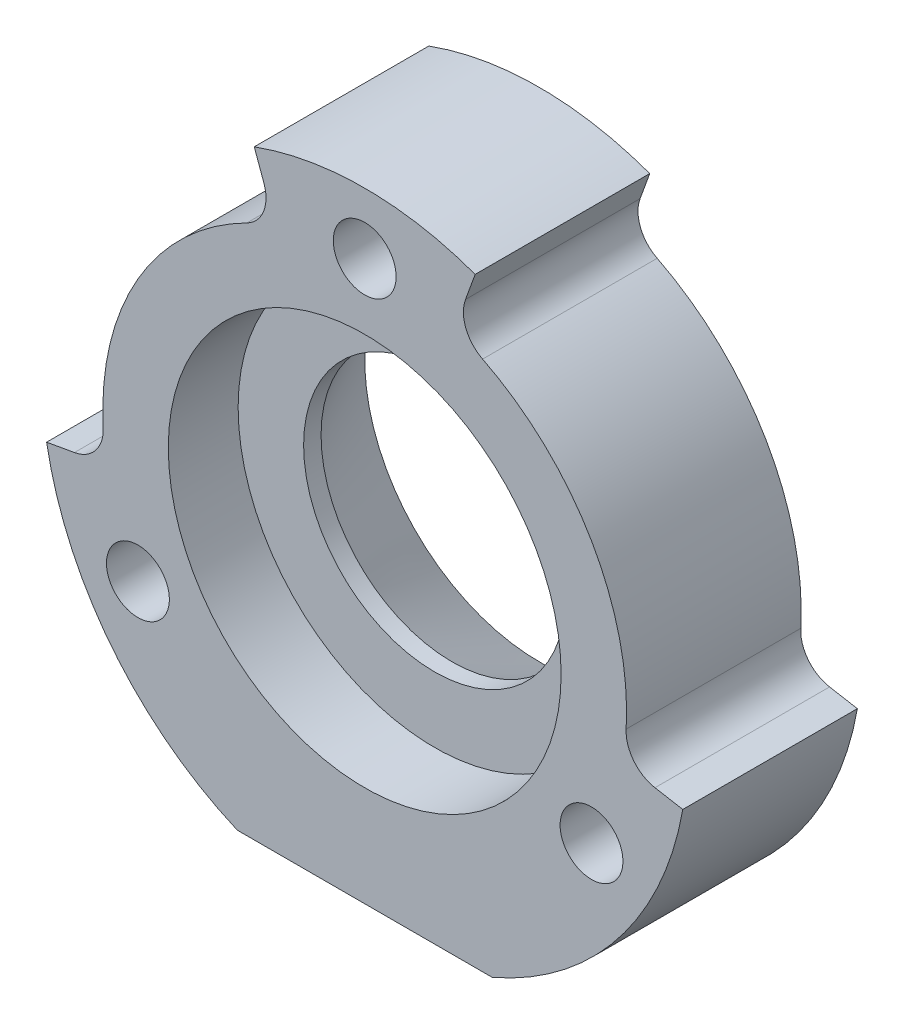
from build123d import *

# Parameters (mm, degrees)
EXTRUDE_1_DEPTH             = 10
CUT_EXTRUDE_1_DEPTH         = 11
CUT_EXTRUDE_2_DEPTH         = 11
HOLE_WIZARD_3_6_3_6_1_D     = 3.6
HOLE_WIZARD_3_6_3_6_1_DEPTH = 10
FILLET_1_R                  = 2


with BuildPart() as part:
    # 草图1 → 凸台-拉伸1 (new body)
    with BuildSketch(Plane.XY.offset(10)):
        with BuildLine():
            Line((-457.29725976, 133), (-442.70274024, 133))
            ThreePointArc((-442.70274024, 133), (-450, 168.5), (-457.29725976, 133))
        make_face()
    extrude(amount=-EXTRUDE_1_DEPTH)

    # 草图2 → 切除-拉伸1 (cut, through all)
    with BuildSketch(Plane(origin=(0, 0, 0), x_dir=(-1, 0, 0), z_dir=(0, 0, -1))):
        with BuildLine():
            Line((431.781056569, 146.787508713), (435.227883705, 147.395277335))
            ThreePointArc((435.227883705, 147.395277335), (437.009618943, 157.5), (444.86969785, 164.095389312))
            Line((444.86969785, 164.095389312), (443.672627348, 167.384313485))
            ThreePointArc((443.672627348, 167.384313485), (433.97853003, 159.25), (431.781056569, 146.787508713))
        make_face()
    extrude(amount=-CUT_EXTRUDE_1_DEPTH, mode=Mode.SUBTRACT)

    # 草图3 → 切除-拉伸2 (cut, through all)
    with BuildSketch(Plane(origin=(0, 0, 0), x_dir=(-1, 0, 0), z_dir=(0, 0, -1))):
        with BuildLine():
            Line((456.327372652, 167.384313485), (455.13030215, 164.095389312))
            ThreePointArc((455.13030215, 164.095389312), (462.990381057, 157.5), (464.772116295, 147.395277335))
            Line((464.772116295, 147.395277335), (468.218943431, 146.787508713))
            ThreePointArc((468.218943431, 146.787508713), (466.02146997, 159.25), (456.327372652, 167.384313485))
        make_face()
    extrude(amount=-CUT_EXTRUDE_2_DEPTH, mode=Mode.SUBTRACT)

    # Ø3.6 (3.6) 直径孔1
    with Locations(Plane(origin=(0, 0, 0), x_dir=(-1, 0, 0), z_dir=(0, 0, -1))):
        with Locations((437.009618943, 142.5), (450, 165), (462.990381057, 142.5)):
            Hole(HOLE_WIZARD_3_6_3_6_1_D / 2, depth=HOLE_WIZARD_3_6_3_6_1_DEPTH)

    # 草图6 → M12 六角头螺栓的柱形沉头孔1 (revolve, cut)
    with BuildSketch(Plane(origin=(-450, 150, 10), x_dir=(0, -1, 0), z_dir=(1, 0, 0))):
        Polygon((0, 0), (0, 10), (10, 10), (7.5, 5), (7.5, 4), (11.25, 4), (11.25, 0), align=None)
    revolve(axis=Axis((-450, 150, 16.35), (0, 0, -1)), mode=Mode.SUBTRACT)

    # 圆角1
    fillet_1_edges = [part.edges().sort_by_distance(p)[0] for p in [
        (-444.86969785, 164.095389312, 5),
        (-435.227883705, 147.395277335, 5),
        (-464.772116295, 147.395277335, 5),
        (-455.13030215, 164.095389312, 5),
    ]]
    fillet(fillet_1_edges, radius=FILLET_1_R)


solid = part.part
